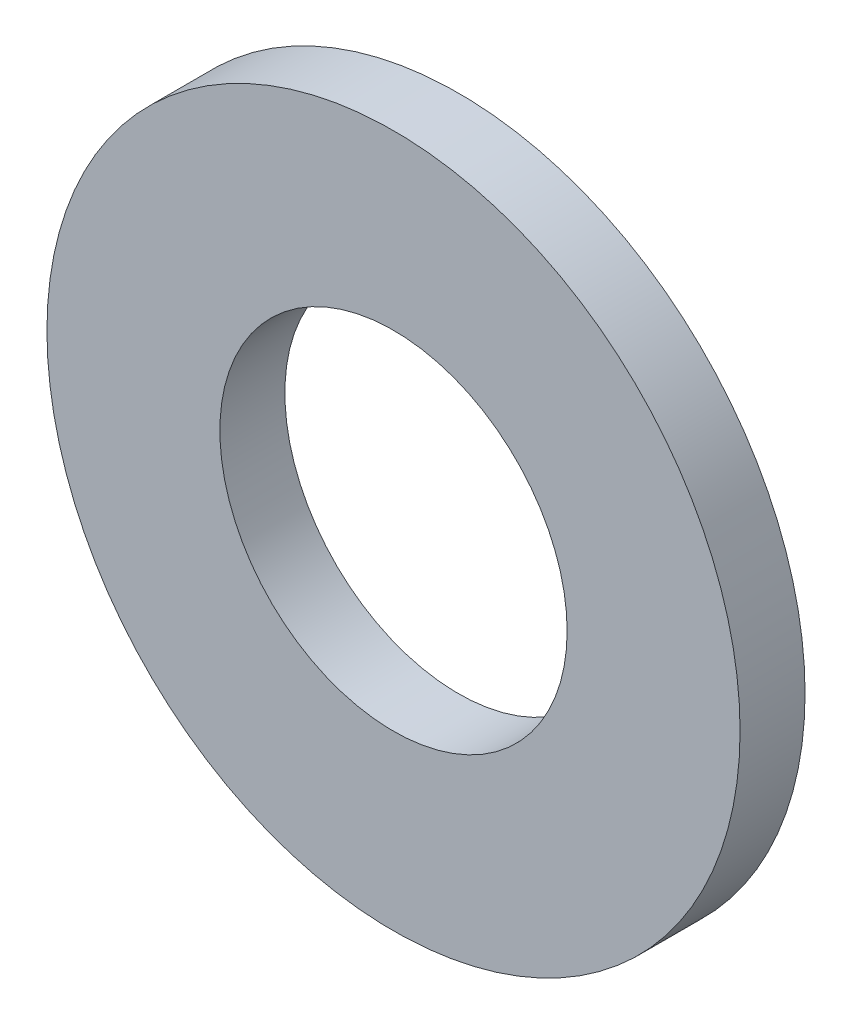
from build123d import *

# Parameters (mm, degrees)
SKETCH1_R      = 12.7
SKETCH1_R_2    = 6.3627
EXTRUDE1_DEPTH = 1.190625


with BuildPart() as part:
    # Sketch1 → Extrude1 (new body, symmetric)
    with BuildSketch(Plane.XY):
        Circle(SKETCH1_R)
        Circle(SKETCH1_R_2, mode=Mode.SUBTRACT)
    extrude(amount=EXTRUDE1_DEPTH, both=True)


solid = part.part
